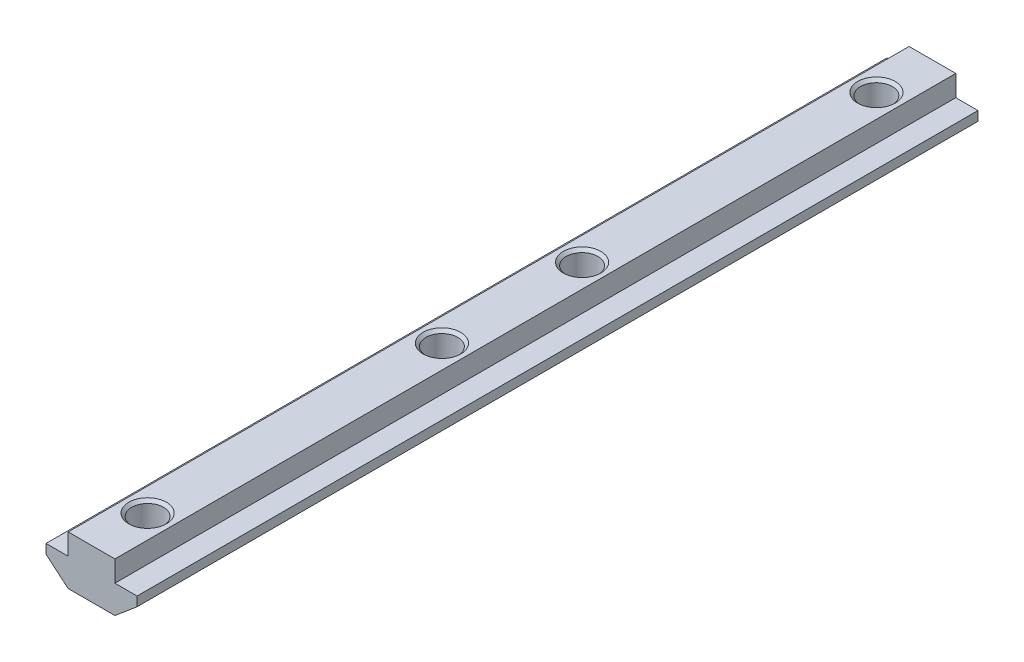
from build123d import *

# Parameters (mm, degrees)
EXTRUDE_1_DEPTH            = 90
HOLE_WIZARD_M81_AT_2_COUNT = 2
HOLE_WIZARD_M81_AT_2_PITCH = 63
HOLE_WIZARD_M81_AT_3_COUNT = 2
HOLE_WIZARD_M81_AT_3_PITCH = 93
HOLE_WIZARD_M81_AT_4_COUNT = 2
HOLE_WIZARD_M81_AT_4_PITCH = 156


with BuildPart() as part:
    # Эскиз1 → Бобышка-Вытянуть1 (new body, symmetric)
    with BuildSketch(Plane.XY):
        Polygon((5, 0), (-5, 0), (-5, -4.5), (-9.75, -4.5), (-9.75, -6.5), (-5, -10.5), (5, -10.5), (9.75, -6.5), (9.75, -4.5), (5, -4.5), align=None)
    extrude(amount=EXTRUDE_1_DEPTH, both=True)

    # Эскиз8 → Отверстие обработанное метчиком M81 (revolve, cut)
    with BuildSketch(Plane(origin=(0, 0, -78), x_dir=(0, 0, 1), z_dir=(1, 0, 0))):
        Polygon((0, 0), (0, 10.5), (4.025, 10.5), (3.4, 9.875), (3.4, 0.625), (4.025, 0), align=None)
    hole_wizard_m81 = revolve(axis=Axis((0, 6.35, -78), (0, -1, 0)), mode=Mode.SUBTRACT)

    # Отверстие обработанное метчиком M81 at 2: Отверстие обработанное метчиком M81 ×2
    with Locations(*[(0, 0, i * HOLE_WIZARD_M81_AT_2_PITCH) for i in range(1, HOLE_WIZARD_M81_AT_2_COUNT)]):
        add(hole_wizard_m81, mode=Mode.SUBTRACT)

    # Отверстие обработанное метчиком M81 at 3: Отверстие обработанное метчиком M81 ×2
    with Locations(*[(0, 0, i * HOLE_WIZARD_M81_AT_3_PITCH) for i in range(1, HOLE_WIZARD_M81_AT_3_COUNT)]):
        add(hole_wizard_m81, mode=Mode.SUBTRACT)

    # Отверстие обработанное метчиком M81 at 4: Отверстие обработанное метчиком M81 ×2
    with Locations(*[(0, 0, i * HOLE_WIZARD_M81_AT_4_PITCH) for i in range(1, HOLE_WIZARD_M81_AT_4_COUNT)]):
        add(hole_wizard_m81, mode=Mode.SUBTRACT)


solid = part.part
